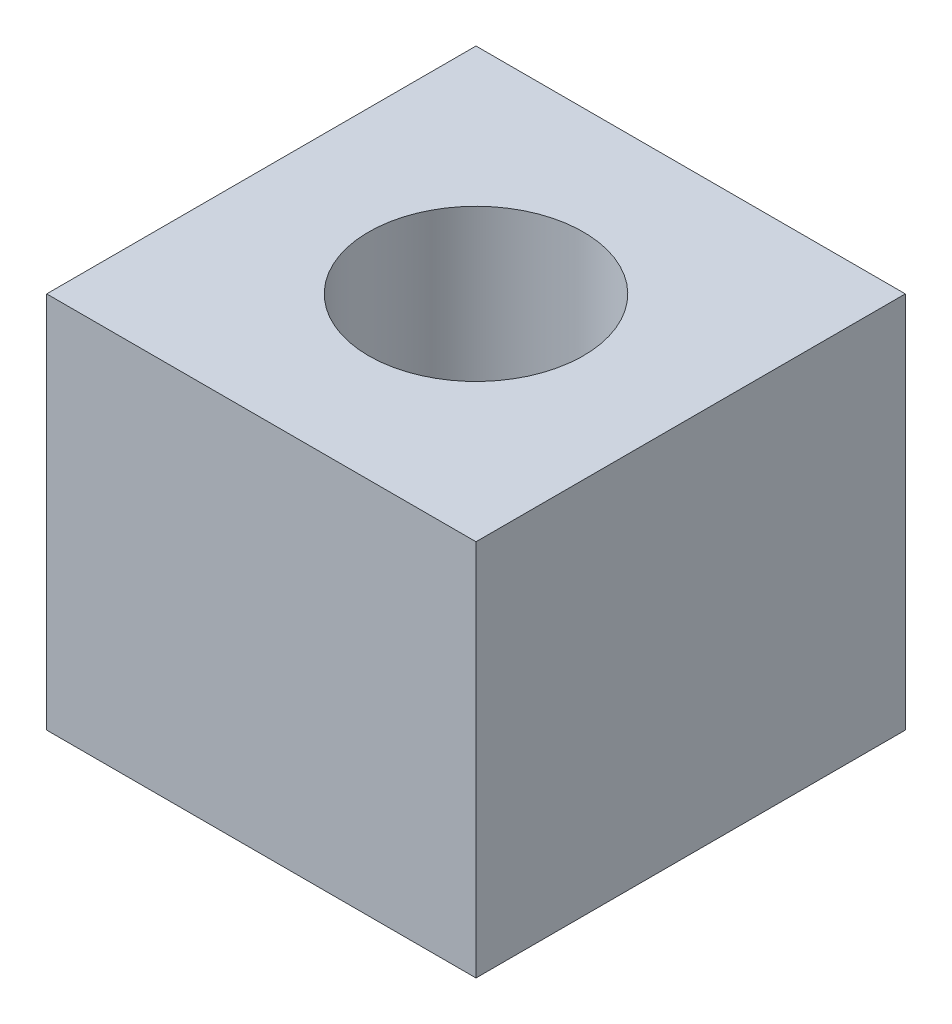
from build123d import *

# Parameters (mm, degrees)
SKETCH1_W           = 25.4
SKETCH1_H           = 25.4
BOSS_EXTRUDE1_DEPTH = 22.352
SKETCH2_R           = 6.35
CUT_EXTRUDE1_DEPTH  = 25.4


with BuildPart() as part:
    # Sketch1 → Boss-Extrude1 (new body)
    with BuildSketch(Plane(origin=(0, 0, 0), x_dir=(1, 0, 0), z_dir=(0, 1, 0))):
        Rectangle(SKETCH1_W, SKETCH1_H)
    extrude(amount=BOSS_EXTRUDE1_DEPTH)

    # Sketch2 → Cut-Extrude1 (cut)
    with BuildSketch(Plane(origin=(0, 22.352, 0), x_dir=(1, 0, 0), z_dir=(0, 1, 0))):
        Circle(SKETCH2_R)
    extrude(amount=-CUT_EXTRUDE1_DEPTH, mode=Mode.SUBTRACT)


solid = part.part
